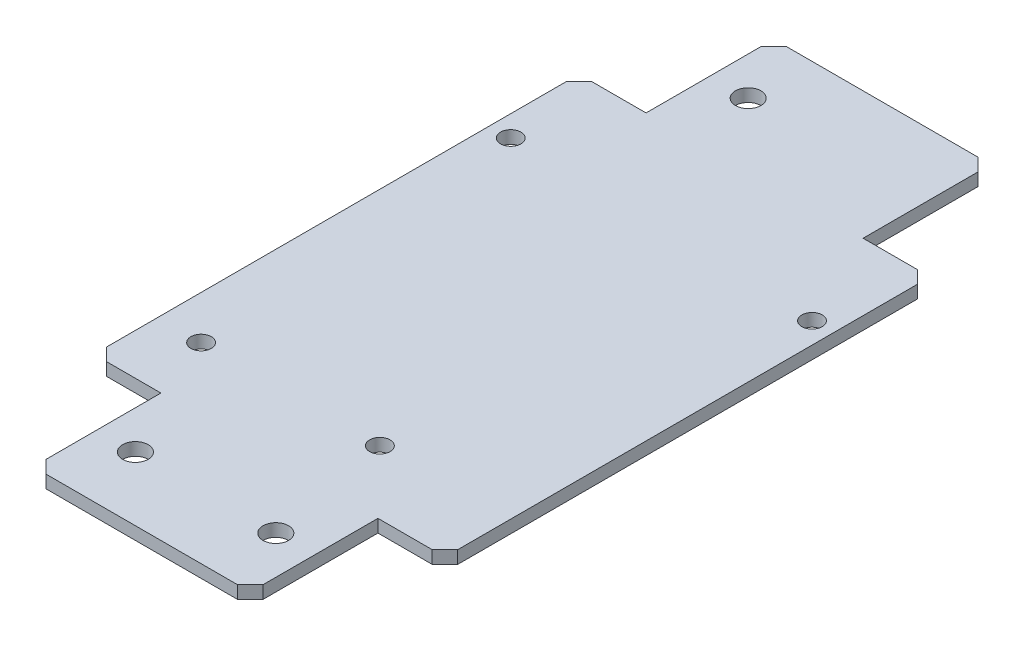
from build123d import *

# Parameters (mm, degrees)
SKETCH1_R           = 2
BOSS_EXTRUDE1_DEPTH = 2
SKETCH2_R           = 1.6
CUT_EXTRUDE1_DEPTH  = 10
CHAMFER1_SIZE       = 2


with BuildPart() as part:
    # Sketch1 → Boss-Extrude1 (new body)
    with BuildSketch(Plane(origin=(0, 50.662802213, 0), x_dir=(1, 0, 0), z_dir=(0, 1, 0))):
        Polygon((-85.703232371, -20), (-85.703232371, -40), (-96.203232371, -40), (-96.203232371, -116), (-85.703232371, -116), (-85.703232371, -136), (-51.703232371, -136), (-51.703232371, -116), (-41.203232371, -116), (-41.203232371, -40), (-51.703232371, -40), (-51.703232371, -20), align=None)
        with Locations((-79.703232371, -30)):
            Circle(SKETCH1_R, mode=Mode.SUBTRACT)
        with Locations((-79.703232371, -126)):
            Circle(SKETCH1_R, mode=Mode.SUBTRACT)
        with Locations((-57.703232371, -126)):
            Circle(SKETCH1_R, mode=Mode.SUBTRACT)
    extrude(amount=BOSS_EXTRUDE1_DEPTH)

    # Sketch2 → Cut-Extrude1 (cut)
    with BuildSketch(Plane(origin=(0, 52.662802213, 0), x_dir=(1, 0, 0), z_dir=(0, 1, 0))):
        with Locations((-92.903232371, -54)):
            Circle(SKETCH2_R)
        with Locations((-44.503232371, -55.2)):
            Circle(SKETCH2_R)
        with Locations((-89.403232371, -106)):
            Circle(SKETCH2_R)
        with Locations((-61.403232371, -106)):
            Circle(SKETCH2_R)
    extrude(amount=-CUT_EXTRUDE1_DEPTH, mode=Mode.SUBTRACT)

    # Chamfer1
    chamfer1_edges = [part.edges().sort_by_distance(p)[0] for p in [
        (-51.703232371, 51.662802213, 20),
        (-41.203232371, 51.662802213, 40),
        (-41.203232371, 51.662802213, 116),
        (-51.703232371, 51.662802213, 136),
        (-85.703232371, 51.662802213, 136),
        (-96.203232371, 51.662802213, 116),
        (-96.203232371, 51.662802213, 40),
        (-85.703232371, 51.662802213, 20),
    ]]
    chamfer(chamfer1_edges, length=CHAMFER1_SIZE)


solid = part.part
